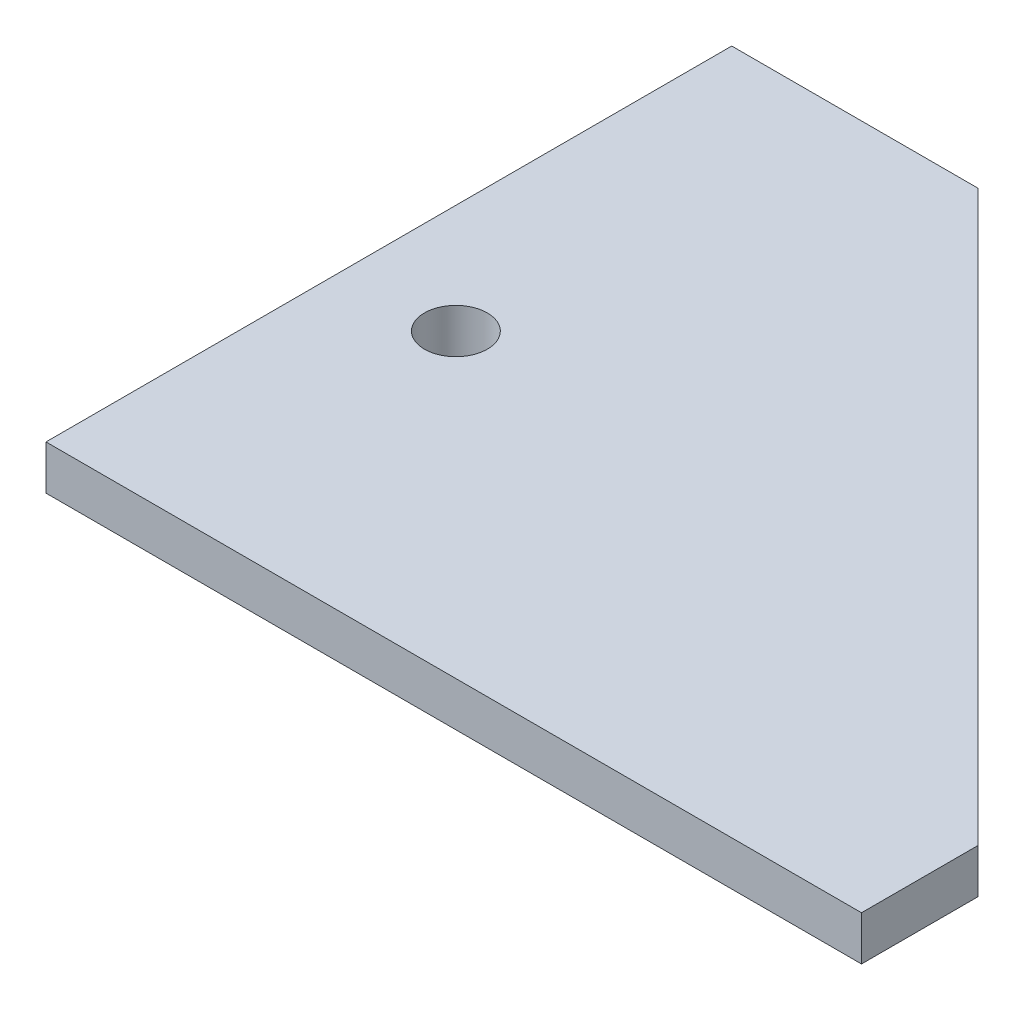
from build123d import *

# Parameters (mm, degrees)
BOSS_EXTRUDE1_DEPTH = 38.1
SKETCH2_R           = 27
CUT_EXTRUDE1_DEPTH  = 39.1


with BuildPart() as part:
    # Sketch1 → Boss-Extrude1 (new body)
    with BuildSketch(Plane(origin=(0, 0, 0), x_dir=(1, 0, 0), z_dir=(0, 1, 0))):
        Polygon((-138.61, 294.305), (350, -194.305), (350, -294.305), (-350, -294.305), (-350, 294.305), align=None)
    extrude(amount=BOSS_EXTRUDE1_DEPTH)

    # Sketch2 → Cut-Extrude1 (cut, through all)
    with BuildSketch(Plane(origin=(0, 0, 0), x_dir=(-1, 0, 0), z_dir=(0, -1, 0))):
        with Locations((256.500204402, -35.980503112)):
            Circle(SKETCH2_R)
    extrude(amount=-CUT_EXTRUDE1_DEPTH, mode=Mode.SUBTRACT)


solid = part.part
